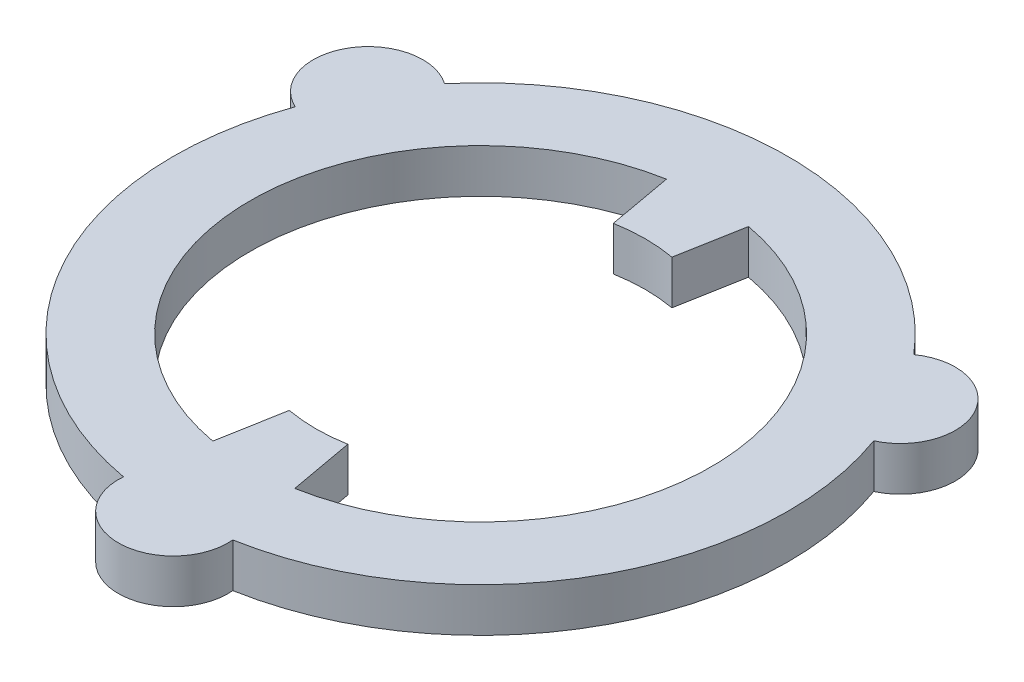
from build123d import *

# Parameters (mm, degrees)
SALIENTE_EXTRUIR1_DEPTH = 2


with BuildPart() as part:
    # Croquis1 → Saliente-Extruir1 (new body)
    with BuildSketch(Plane(origin=(0, 0, 0), x_dir=(1, 0, 0), z_dir=(0, 1, 0))):
        with BuildLine():
            ThreePointArc((-13.17605398, 4.731976493), (-12.124355653, -7), (-2.490015137, -13.776785714))
            ThreePointArc((-2.490015137, -13.776785714), (0, -16.5), (2.490015137, -13.776785714))
            ThreePointArc((2.490015137, -13.776785714), (12.124355653, -7), (13.17605398, 4.731976493))
            ThreePointArc((13.17605398, 4.731976493), (14.289419162, 8.25), (10.686038843, 9.044809222))
            ThreePointArc((10.686038843, 9.044809222), (0, 14), (-10.686038843, 9.044809222))
            ThreePointArc((-10.686038843, 9.044809222), (-14.289419162, 8.25), (-13.17605398, 4.731976493))
        make_face()
        with BuildLine():
            Line((1.867511353, -10.332589286), (1.333936681, -7.380420918))
            ThreePointArc((1.333936681, -7.380420918), (0, -7.5), (-1.333936681, -7.380420918))
            Line((-1.333936681, -7.380420918), (-1.867511353, -10.332589286))
            ThreePointArc((-1.867511353, -10.332589286), (-10.5, 0), (-1.867511353, 10.332589286))
            Line((-1.867511353, 10.332589286), (-1.333936681, 7.380420918))
            ThreePointArc((-1.333936681, 7.380420918), (0, 7.5), (1.333936681, 7.380420918))
            Line((1.333936681, 7.380420918), (1.867511353, 10.332589286))
            ThreePointArc((1.867511353, 10.332589286), (10.5, 0), (1.867511353, -10.332589286))
        make_face(mode=Mode.SUBTRACT)
    extrude(amount=SALIENTE_EXTRUIR1_DEPTH)


solid = part.part
